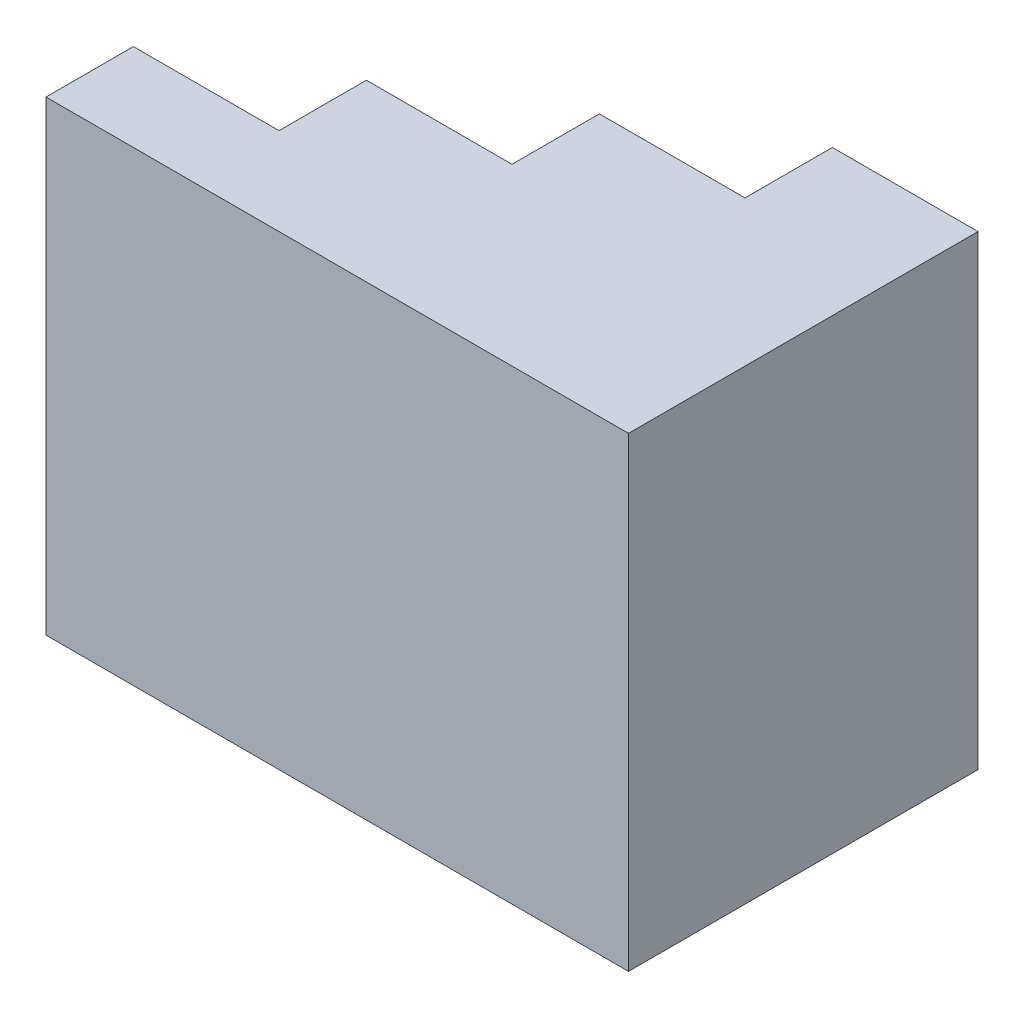
from build123d import *

# Parameters (mm, degrees)
BOSS_EXTRUDE1_DEPTH = 60
SKETCH1_3_W         = 100
SKETCH1_3_H         = 60
BOSS_EXTRUDE2_DEPTH = 20


with BuildPart() as part:
    # Sketch1 → Boss-Extrude1 (new body)
    with BuildSketch(Plane(origin=(0, 0, 0), x_dir=(1, 0, 0), z_dir=(0, 1, 0))):
        Polygon((-25, -15), (-50, -15), (-50, -30), (50, -30), (50, 30), (25, 30), (25, 15), (0, 15), (0, 0), (-25, 0), align=None)
    extrude(amount=BOSS_EXTRUDE1_DEPTH)

    # Sketch1_3 → Boss-Extrude2 (add)
    with BuildSketch(Plane(origin=(0, 0, 0), x_dir=(1, 0, 0), z_dir=(0, 1, 0))):
        Rectangle(SKETCH1_3_W, SKETCH1_3_H)
    extrude(amount=-BOSS_EXTRUDE2_DEPTH)


solid = part.part
